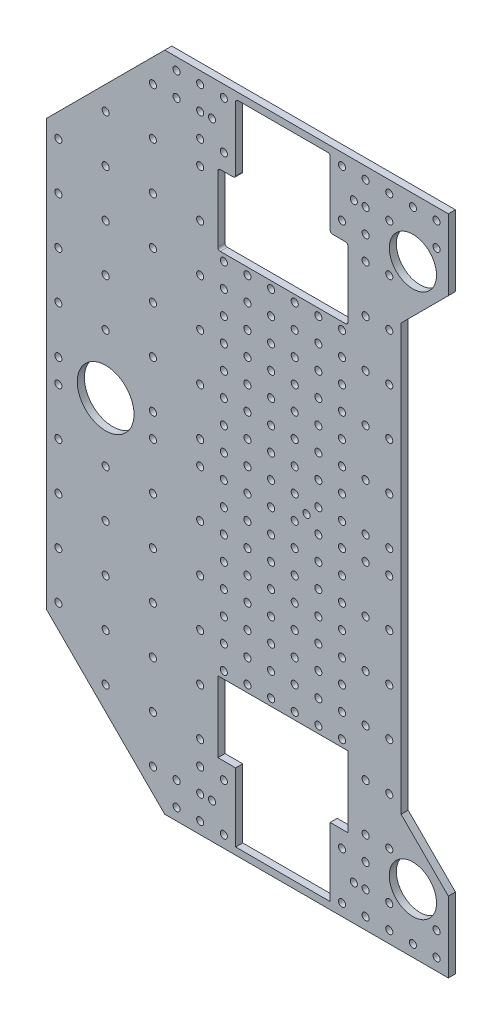
from build123d import *

# Parameters (mm, degrees)
SKETCH1_R                           = 1.5
MAIN_DEPTH                          = 3
MOTORCODERLEFTHOLE_DEPTH            = 179.070210872
FILLET1_R                           = 1
SKETCH7_R                           = 1.5
MOTORFIXHOLES_DEPTH                 = 179.070210872
MOTORFIXHOLELPATTERN_COUNT          = 8
MOTORFIXHOLELPATTERN_PITCH          = 10
SKETCH8_R                           = 1.5
LINEARBALLFIX_DEPTH                 = 179.070210872
LINEARBALLFIX2_COUNT                = 2
LINEARBALLFIX2_PITCH                = 60
SKETCH4_R                           = 1.5
BOTTOMLEFTHOLE_DEPTH                = 179.070210872
BOTTOMLEFTHOLELPATTERN_COUNT        = 9
BOTTOMLEFTHOLELPATTERN_PITCH        = 20
SKETCH5_R                           = 1.5
BOTTOMLEFTHOLE2_DEPTH               = 179.070210872
BOTTOMTOTOPPATTERN_COPY_1_SKETCH_R  = 1.5
BOTTOMTOTOPPATTERN_COPY_1_DEPTH     = 179.070210872
BOTTOMTOTOPPATTERN_COPY_2_SKETCH_R  = 1.5
BOTTOMTOTOPPATTERN_COPY_2_DEPTH     = 179.070210872
BOTTOMTOTOPPATTERN_COPY_3_SKETCH_R  = 1.5
BOTTOMTOTOPPATTERN_COPY_3_DEPTH     = 179.070210872
BOTTOMTOTOPPATTERN_COPY_4_SKETCH_R  = 1.5
BOTTOMTOTOPPATTERN_COPY_4_DEPTH     = 179.070210872
BOTTOMTOTOPPATTERN_COPY_5_SKETCH_R  = 1.5
BOTTOMTOTOPPATTERN_COPY_5_DEPTH     = 179.070210872
BOTTOMTOTOPPATTERN_COPY_6_SKETCH_R  = 1.5
BOTTOMTOTOPPATTERN_COPY_6_DEPTH     = 179.070210872
BOTTOMTOTOPPATTERN_COPY_7_SKETCH_R  = 1.5
BOTTOMTOTOPPATTERN_COPY_7_DEPTH     = 179.070210872
BOTTOMTOTOPPATTERN_COPY_8_SKETCH_R  = 1.5
BOTTOMTOTOPPATTERN_COPY_8_DEPTH     = 179.070210872
BOTTOMTOTOPPATTERN_COPY_9_SKETCH_R  = 1.5
BOTTOMTOTOPPATTERN_COPY_9_DEPTH     = 179.070210872
BOTTOMTOTOPPATTERN_COPY_10_SKETCH_R = 1.5
BOTTOMTOTOPPATTERN_COPY_10_DEPTH    = 179.070210872
BOTTOMTOTOPPATTERN_COPY_11_SKETCH_R = 1.5
BOTTOMTOTOPPATTERN_COPY_11_DEPTH    = 179.070210872
BOTTOMTOTOPPATTERN_COPY_12_SKETCH_R = 1.5
BOTTOMTOTOPPATTERN_COPY_12_DEPTH    = 179.070210872
BOTTOMTOTOPPATTERN_COPY_13_SKETCH_R = 1.5
BOTTOMTOTOPPATTERN_COPY_13_DEPTH    = 179.070210872
BOTTOMTOTOPPATTERN_COPY_14_SKETCH_R = 1.5
BOTTOMTOTOPPATTERN_COPY_14_DEPTH    = 179.070210872
BOTTOMTOTOPPATTERN_COPY_15_SKETCH_R = 1.5
BOTTOMTOTOPPATTERN_COPY_15_DEPTH    = 179.070210872
BOTTOMTOTOPPATTERN_COPY_16_SKETCH_R = 1.5
BOTTOMTOTOPPATTERN_COPY_16_DEPTH    = 179.070210872
BOTTOMTOTOPPATTERN_COPY_17_SKETCH_R = 1.5
BOTTOMTOTOPPATTERN_COPY_17_DEPTH    = 179.070210872
BOTTOMTOTOPPATTERN_COPY_18_SKETCH_R = 1.5
BOTTOMTOTOPPATTERN_COPY_18_DEPTH    = 179.070210872
BOTTOMTOTOPPATTERN_COPY_19_SKETCH_R = 1.5
BOTTOMTOTOPPATTERN_COPY_19_DEPTH    = 179.070210872
BOTTOMTOTOPPATTERN_COPY_20_SKETCH_R = 1.5
BOTTOMTOTOPPATTERN_COPY_20_DEPTH    = 179.070210872
BOTTOMTOTOPPATTERN_COPY_21_SKETCH_R = 1.5
BOTTOMTOTOPPATTERN_COPY_21_DEPTH    = 179.070210872
BOTTOMTOTOPPATTERN_COPY_22_SKETCH_R = 1.5
BOTTOMTOTOPPATTERN_COPY_22_DEPTH    = 179.070210872
BOTTOMTOTOPPATTERN_COPY_23_SKETCH_R = 1.5
BOTTOMTOTOPPATTERN_COPY_23_DEPTH    = 179.070210872
BOTTOMTOTOPPATTERN_COPY_24_SKETCH_R = 1.5
BOTTOMTOTOPPATTERN_COPY_24_DEPTH    = 179.070210872
BOTTOMTOTOPPATTERN_COPY_25_SKETCH_R = 1.5
BOTTOMTOTOPPATTERN_COPY_25_DEPTH    = 179.070210872
BOTTOMTOTOPPATTERN_COPY_26_SKETCH_R = 1.5
BOTTOMTOTOPPATTERN_COPY_26_DEPTH    = 179.070210872
BOTTOMTOTOPPATTERN_COPY_27_SKETCH_R = 1.5
BOTTOMTOTOPPATTERN_COPY_27_DEPTH    = 179.070210872
LPATTERN3_COUNT                     = 2
LPATTERN3_PITCH                     = 10
FRONTHOLES_COPY_1_SKETCH_R          = 1.5
FRONTHOLES_COPY_1_DEPTH             = 179.070210872
FRONTHOLES_COPY_2_SKETCH_R          = 1.5
FRONTHOLES_COPY_2_DEPTH             = 179.070210872
FRONTHOLES_COPY_3_SKETCH_R          = 1.5
FRONTHOLES_COPY_3_DEPTH             = 179.070210872
FRONTHOLES_COPY_4_SKETCH_R          = 1.5
FRONTHOLES_COPY_4_DEPTH             = 179.070210872
FRONTHOLES_COPY_5_SKETCH_R          = 1.5
FRONTHOLES_COPY_5_DEPTH             = 179.070210872
FRONTHOLES_COPY_6_SKETCH_R          = 1.5
FRONTHOLES_COPY_6_DEPTH             = 179.070210872
FRONTHOLES_COPY_7_SKETCH_R          = 1.5
FRONTHOLES_COPY_7_DEPTH             = 179.070210872
FRONTHOLES_COPY_8_SKETCH_R          = 1.5
FRONTHOLES_COPY_8_DEPTH             = 179.070210872
FRONTHOLES_COPY_9_SKETCH_R          = 1.5
FRONTHOLES_COPY_9_DEPTH             = 179.070210872
SKETCH9_R                           = 1.5
CUT_EXTRUDE2_DEPTH                  = 179.070210872
LPATTERN6_COPY_1_SKETCH_R           = 1.5
LPATTERN6_COPY_1_DEPTH              = 179.070210872
LPATTERN6_COPY_2_SKETCH_R           = 1.5
LPATTERN6_COPY_2_DEPTH              = 179.070210872
LPATTERN6_COPY_3_SKETCH_R           = 1.5
LPATTERN6_COPY_3_DEPTH              = 179.070210872
LPATTERN6_COPY_4_SKETCH_R           = 1.5
LPATTERN6_COPY_4_DEPTH              = 179.070210872
LPATTERN6_COPY_5_SKETCH_R           = 1.5
LPATTERN6_COPY_5_DEPTH              = 179.070210872
LPATTERN6_COPY_6_SKETCH_R           = 1.5
LPATTERN6_COPY_6_DEPTH              = 179.070210872
LPATTERN6_COPY_7_SKETCH_R           = 1.5
LPATTERN6_COPY_7_DEPTH              = 179.070210872
LPATTERN6_COPY_8_SKETCH_R           = 1.5
LPATTERN6_COPY_8_DEPTH              = 179.070210872
LPATTERN6_COPY_9_SKETCH_R           = 1.5
LPATTERN6_COPY_9_DEPTH              = 179.070210872
MIRROR1_COPY_1_SKETCH_R             = 1.5
MIRROR1_COPY_1_DEPTH                = 179.070210872
MIRROR1_COPY_2_SKETCH_R             = 1.5
MIRROR1_COPY_2_DEPTH                = 179.070210872
MIRROR1_COPY_3_SKETCH_R             = 1.5
MIRROR1_COPY_3_DEPTH                = 179.070210872
MIRROR1_COPY_4_SKETCH_R             = 1.5
MIRROR1_COPY_4_DEPTH                = 179.070210872
MIRROR1_COPY_5_SKETCH_R             = 1.5
MIRROR1_COPY_5_DEPTH                = 179.070210872
MIRROR1_COPY_6_SKETCH_R             = 1.5
MIRROR1_COPY_6_DEPTH                = 179.070210872
MIRROR1_COPY_7_SKETCH_R             = 1.5
MIRROR1_COPY_7_DEPTH                = 179.070210872
MIRROR1_COPY_8_SKETCH_R             = 1.5
MIRROR1_COPY_8_DEPTH                = 179.070210872
MIRROR1_COPY_9_SKETCH_R             = 1.5
MIRROR1_COPY_9_DEPTH                = 179.070210872
MIRROR1_COPY_10_SKETCH_R            = 1.5
MIRROR1_COPY_10_DEPTH               = 179.070210872
MIRROR1_COPY_11_SKETCH_R            = 1.5
MIRROR1_COPY_11_DEPTH               = 179.070210872
MIRROR1_COPY_12_SKETCH_R            = 1.5
MIRROR1_COPY_12_DEPTH               = 179.070210872
MIRROR1_COPY_13_SKETCH_R            = 1.5
MIRROR1_COPY_13_DEPTH               = 179.070210872
MIRROR1_COPY_14_SKETCH_R            = 1.5
MIRROR1_COPY_14_DEPTH               = 179.070210872
MIRROR1_COPY_15_SKETCH_R            = 1.5
MIRROR1_COPY_15_DEPTH               = 179.070210872
MIRROR1_COPY_16_SKETCH_R            = 1.5
MIRROR1_COPY_16_DEPTH               = 179.070210872
MIRROR1_COPY_17_SKETCH_R            = 1.5
MIRROR1_COPY_17_DEPTH               = 179.070210872
MIRROR1_COPY_18_SKETCH_R            = 1.5
MIRROR1_COPY_18_DEPTH               = 179.070210872
MIRROR1_COPY_19_SKETCH_R            = 1.5
MIRROR1_COPY_19_DEPTH               = 179.070210872
MIRROR1_COPY_20_SKETCH_R            = 1.5
MIRROR1_COPY_20_DEPTH               = 179.070210872
MIRROR1_COPY_21_SKETCH_R            = 1.5
MIRROR1_COPY_21_DEPTH               = 179.070210872
MIRROR1_COPY_22_SKETCH_R            = 1.5
MIRROR1_COPY_22_DEPTH               = 179.070210872
MIRROR1_COPY_23_SKETCH_R            = 1.5
MIRROR1_COPY_23_DEPTH               = 179.070210872
MIRROR1_COPY_24_SKETCH_R            = 1.5
MIRROR1_COPY_24_DEPTH               = 179.070210872
MIRROR1_COPY_25_SKETCH_R            = 1.5
MIRROR1_COPY_25_DEPTH               = 179.070210872
MIRROR1_COPY_26_SKETCH_R            = 1.5
MIRROR1_COPY_26_DEPTH               = 179.070210872
MIRROR1_COPY_27_SKETCH_R            = 1.5
MIRROR1_COPY_27_DEPTH               = 179.070210872
MIRROR1_COPY_28_SKETCH_R            = 1.5
MIRROR1_COPY_28_DEPTH               = 179.070210872
MIRROR1_COPY_29_SKETCH_R            = 1.5
MIRROR1_COPY_29_DEPTH               = 179.070210872
MIRROR1_COPY_30_SKETCH_R            = 1.5
MIRROR1_COPY_30_DEPTH               = 179.070210872
MIRROR1_COPY_31_SKETCH_R            = 1.5
MIRROR1_COPY_31_DEPTH               = 179.070210872
MIRROR1_COPY_32_SKETCH_R            = 1.5
MIRROR1_COPY_32_DEPTH               = 179.070210872
MIRROR1_COPY_33_SKETCH_R            = 1.5
MIRROR1_COPY_33_DEPTH               = 179.070210872
MIRROR1_COPY_34_SKETCH_R            = 1.5
MIRROR1_COPY_34_DEPTH               = 179.070210872
MIRROR1_COPY_35_SKETCH_R            = 1.5
MIRROR1_COPY_35_DEPTH               = 179.070210872
MIRROR1_COPY_36_SKETCH_R            = 1.5
MIRROR1_COPY_36_DEPTH               = 179.070210872
MIRROR1_COPY_37_SKETCH_R            = 1.5
MIRROR1_COPY_37_DEPTH               = 179.070210872
MIRROR1_COPY_38_SKETCH_R            = 1.5
MIRROR1_COPY_38_DEPTH               = 179.070210872
MIRROR1_COPY_39_SKETCH_R            = 1.5
MIRROR1_COPY_39_DEPTH               = 179.070210872
MIRROR1_COPY_40_SKETCH_R            = 1.5
MIRROR1_COPY_40_DEPTH               = 179.070210872
MIRROR1_COPY_41_SKETCH_R            = 1.5
MIRROR1_COPY_41_DEPTH               = 179.070210872
MIRROR1_COPY_42_SKETCH_R            = 1.5
MIRROR1_COPY_42_DEPTH               = 179.070210872
MIRROR1_COPY_43_SKETCH_R            = 1.5
MIRROR1_COPY_43_DEPTH               = 179.070210872
MIRROR1_COPY_44_SKETCH_R            = 1.5
MIRROR1_COPY_44_DEPTH               = 179.070210872
MIRROR1_COPY_45_SKETCH_R            = 1.5
MIRROR1_COPY_45_DEPTH               = 179.070210872
MIRROR1_COPY_46_SKETCH_R            = 1.5
MIRROR1_COPY_46_DEPTH               = 179.070210872
MIRROR1_COPY_47_SKETCH_R            = 1.5
MIRROR1_COPY_47_DEPTH               = 179.070210872
MIRROR1_COPY_48_SKETCH_R            = 1.5
MIRROR1_COPY_48_DEPTH               = 179.070210872
MIRROR1_COPY_49_SKETCH_R            = 1.5
MIRROR1_COPY_49_DEPTH               = 179.070210872
MIRROR1_COPY_50_SKETCH_R            = 1.5
MIRROR1_COPY_50_DEPTH               = 179.070210872
MIRROR1_COPY_51_SKETCH_R            = 1.5
MIRROR1_COPY_51_DEPTH               = 179.070210872
MIRROR1_COPY_52_SKETCH_R            = 1.5
MIRROR1_COPY_52_DEPTH               = 179.070210872
MIRROR1_COPY_53_SKETCH_R            = 1.5
MIRROR1_COPY_53_DEPTH               = 179.070210872
MIRROR1_COPY_54_SKETCH_R            = 1.5
MIRROR1_COPY_54_DEPTH               = 179.070210872
MIRROR1_COPY_55_SKETCH_R            = 1.5
MIRROR1_COPY_55_DEPTH               = 179.070210872
MIRROR1_COPY_56_SKETCH_R            = 1.5
MIRROR1_COPY_56_DEPTH               = 179.070210872
MIRROR1_COPY_57_SKETCH_R            = 1.5
MIRROR1_COPY_57_DEPTH               = 179.070210872
MIRROR1_COPY_58_SKETCH_R            = 1.5
MIRROR1_COPY_58_DEPTH               = 179.070210872
MIRROR1_COPY_59_SKETCH_R            = 1.5
MIRROR1_COPY_59_DEPTH               = 179.070210872
MIRROR1_COPY_60_SKETCH_R            = 1.5
MIRROR1_COPY_60_DEPTH               = 179.070210872
MIRROR1_COPY_61_SKETCH_R            = 1.5
MIRROR1_COPY_61_DEPTH               = 179.070210872
MIRROR1_COPY_62_SKETCH_R            = 1.5
MIRROR1_COPY_62_DEPTH               = 179.070210872
SKETCH3_R                           = 12
SKETCH3_R_2                         = 10
BIGHOLES_DEPTH                      = 179.070210872


with BuildPart() as part:
    # Sketch1 → Main (new body)
    with BuildSketch(Plane.XY):
        Polygon((-110, 90), (-110, -90), (-60, -140), (60, -140), (60, -110), (40, -90), (40, 90), (60, 110), (60, 140), (-60, 140), align=None)
        Circle(SKETCH1_R, mode=Mode.SUBTRACT)
    extrude(amount=MAIN_DEPTH)

    # Sketch2 → MotorCoderLeftHole (cut, through all)
    with BuildSketch(Plane.XY.offset(3)):
        Polygon((-37.5, 108), (-37.5, 78), (17.5, 78), (17.5, 108), (10, 108), (10, 137), (-30, 137), (-30, 108), align=None)
    motorcoderlefthole = extrude(amount=-MOTORCODERLEFTHOLE_DEPTH, mode=Mode.SUBTRACT)

    # Fillet1
    fillet1_edges = [part.edges().sort_by_distance(p)[0] for p in [
        (-30, 137, 1.5),
        (10, 108, 1.5),
        (17.5, 108, 1.5),
        (10, 137, 1.5),
        (17.5, 78, 1.5),
        (-37.5, 78, 1.5),
        (-37.5, 108, 1.5),
        (-30, 108, 1.5),
    ]]
    fillet(fillet1_edges, radius=FILLET1_R)

    # Sketch7 → MotorFixHoles (cut, through all)
    with BuildSketch(Plane.XY.offset(3)):
        with Locations((-15, 75)):
            Circle(SKETCH7_R)
        with Locations((-25, 75)):
            Circle(SKETCH7_R)
        with Locations((-5, 75)):
            Circle(SKETCH7_R)
        with Locations((-35, 75)):
            Circle(SKETCH7_R)
        with Locations((5, 75)):
            Circle(SKETCH7_R)
        with Locations((15, 75)):
            Circle(SKETCH7_R)
    motorfixholes = extrude(amount=-MOTORFIXHOLES_DEPTH, mode=Mode.SUBTRACT)

    # MotorFixHoleLPattern: MotorFixHoles ×8
    with Locations(*[(0, -i * MOTORFIXHOLELPATTERN_PITCH, 0) for i in range(1, MOTORFIXHOLELPATTERN_COUNT)]):
        add(motorfixholes, mode=Mode.SUBTRACT)

    # Sketch8 → LinearBallFix (cut, through all)
    with BuildSketch(Plane.XY.offset(3)):
        with Locations((-40, 125)):
            Circle(SKETCH8_R)
        with Locations((-45, 115)):
            Circle(SKETCH8_R)
        with Locations((-35, 115)):
            Circle(SKETCH8_R)
        with Locations((-45, 135)):
            Circle(SKETCH8_R)
        with Locations((-35, 135)):
            Circle(SKETCH8_R)
    linearballfix = extrude(amount=-LINEARBALLFIX_DEPTH, mode=Mode.SUBTRACT)

    # LinearBallFix2: LinearBallFix ×2
    with Locations(*[(i * LINEARBALLFIX2_PITCH, 0, 0) for i in range(1, LINEARBALLFIX2_COUNT)]):
        add(linearballfix, mode=Mode.SUBTRACT)

    # Sketch4 → BottomLeftHole (cut, through all)
    with BuildSketch(Plane.XY.offset(3)):
        with Locations((-105, 5)):
            Circle(SKETCH4_R)
    bottomlefthole = extrude(amount=-BOTTOMLEFTHOLE_DEPTH, mode=Mode.SUBTRACT)

    # BottomLeftHoleLPattern: BottomLeftHole ×9
    with Locations(*[(0, i * BOTTOMLEFTHOLELPATTERN_PITCH, 0) for i in range(1, BOTTOMLEFTHOLELPATTERN_COUNT)]):
        add(bottomlefthole, mode=Mode.SUBTRACT)

    # Sketch5 → BottomLeftHole2 (cut, through all)
    with BuildSketch(Plane.XY.offset(3)):
        with Locations((-55, 135)):
            Circle(SKETCH5_R)
        with Locations((35, 135)):
            Circle(SKETCH5_R)
        with Locations((55, 135)):
            Circle(SKETCH5_R)
    bottomlefthole2 = extrude(amount=-BOTTOMLEFTHOLE2_DEPTH, mode=Mode.SUBTRACT)

    # BottomToTopPattern copy 1 sketch → BottomToTopPattern copy 1 (cut, through all)
    with BuildSketch(Plane(origin=(20, 20, 3), x_dir=(1, 0, 0), z_dir=(0, 0, 1))):
        with Locations((-105, 5)):
            Circle(BOTTOMTOTOPPATTERN_COPY_1_SKETCH_R)
    extrude(amount=-BOTTOMTOTOPPATTERN_COPY_1_DEPTH, mode=Mode.SUBTRACT)

    # BottomToTopPattern copy 2 sketch → BottomToTopPattern copy 2 (cut, through all)
    with BuildSketch(Plane(origin=(40, 20, 3), x_dir=(1, 0, 0), z_dir=(0, 0, 1))):
        with Locations((-105, 5)):
            Circle(BOTTOMTOTOPPATTERN_COPY_2_SKETCH_R)
    extrude(amount=-BOTTOMTOTOPPATTERN_COPY_2_DEPTH, mode=Mode.SUBTRACT)

    # BottomToTopPattern copy 3 sketch → BottomToTopPattern copy 3 (cut, through all)
    with BuildSketch(Plane(origin=(60, 20, 3), x_dir=(1, 0, 0), z_dir=(0, 0, 1))):
        with Locations((-105, 5)):
            Circle(BOTTOMTOTOPPATTERN_COPY_3_SKETCH_R)
    extrude(amount=-BOTTOMTOTOPPATTERN_COPY_3_DEPTH, mode=Mode.SUBTRACT)

    # BottomToTopPattern copy 4 sketch → BottomToTopPattern copy 4 (cut, through all)
    with BuildSketch(Plane(origin=(20, 40, 3), x_dir=(1, 0, 0), z_dir=(0, 0, 1))):
        with Locations((-105, 5)):
            Circle(BOTTOMTOTOPPATTERN_COPY_4_SKETCH_R)
    extrude(amount=-BOTTOMTOTOPPATTERN_COPY_4_DEPTH, mode=Mode.SUBTRACT)

    # BottomToTopPattern copy 5 sketch → BottomToTopPattern copy 5 (cut, through all)
    with BuildSketch(Plane(origin=(40, 40, 3), x_dir=(1, 0, 0), z_dir=(0, 0, 1))):
        with Locations((-105, 5)):
            Circle(BOTTOMTOTOPPATTERN_COPY_5_SKETCH_R)
    extrude(amount=-BOTTOMTOTOPPATTERN_COPY_5_DEPTH, mode=Mode.SUBTRACT)

    # BottomToTopPattern copy 6 sketch → BottomToTopPattern copy 6 (cut, through all)
    with BuildSketch(Plane(origin=(60, 40, 3), x_dir=(1, 0, 0), z_dir=(0, 0, 1))):
        with Locations((-105, 5)):
            Circle(BOTTOMTOTOPPATTERN_COPY_6_SKETCH_R)
    extrude(amount=-BOTTOMTOTOPPATTERN_COPY_6_DEPTH, mode=Mode.SUBTRACT)

    # BottomToTopPattern copy 7 sketch → BottomToTopPattern copy 7 (cut, through all)
    with BuildSketch(Plane(origin=(20, 60, 3), x_dir=(1, 0, 0), z_dir=(0, 0, 1))):
        with Locations((-105, 5)):
            Circle(BOTTOMTOTOPPATTERN_COPY_7_SKETCH_R)
    extrude(amount=-BOTTOMTOTOPPATTERN_COPY_7_DEPTH, mode=Mode.SUBTRACT)

    # BottomToTopPattern copy 8 sketch → BottomToTopPattern copy 8 (cut, through all)
    with BuildSketch(Plane(origin=(40, 60, 3), x_dir=(1, 0, 0), z_dir=(0, 0, 1))):
        with Locations((-105, 5)):
            Circle(BOTTOMTOTOPPATTERN_COPY_8_SKETCH_R)
    extrude(amount=-BOTTOMTOTOPPATTERN_COPY_8_DEPTH, mode=Mode.SUBTRACT)

    # BottomToTopPattern copy 9 sketch → BottomToTopPattern copy 9 (cut, through all)
    with BuildSketch(Plane(origin=(60, 60, 3), x_dir=(1, 0, 0), z_dir=(0, 0, 1))):
        with Locations((-105, 5)):
            Circle(BOTTOMTOTOPPATTERN_COPY_9_SKETCH_R)
    extrude(amount=-BOTTOMTOTOPPATTERN_COPY_9_DEPTH, mode=Mode.SUBTRACT)

    # BottomToTopPattern copy 10 sketch → BottomToTopPattern copy 10 (cut, through all)
    with BuildSketch(Plane(origin=(20, 80, 3), x_dir=(1, 0, 0), z_dir=(0, 0, 1))):
        with Locations((-105, 5)):
            Circle(BOTTOMTOTOPPATTERN_COPY_10_SKETCH_R)
    extrude(amount=-BOTTOMTOTOPPATTERN_COPY_10_DEPTH, mode=Mode.SUBTRACT)

    # BottomToTopPattern copy 11 sketch → BottomToTopPattern copy 11 (cut, through all)
    with BuildSketch(Plane(origin=(40, 80, 3), x_dir=(1, 0, 0), z_dir=(0, 0, 1))):
        with Locations((-105, 5)):
            Circle(BOTTOMTOTOPPATTERN_COPY_11_SKETCH_R)
    extrude(amount=-BOTTOMTOTOPPATTERN_COPY_11_DEPTH, mode=Mode.SUBTRACT)

    # BottomToTopPattern copy 12 sketch → BottomToTopPattern copy 12 (cut, through all)
    with BuildSketch(Plane(origin=(60, 80, 3), x_dir=(1, 0, 0), z_dir=(0, 0, 1))):
        with Locations((-105, 5)):
            Circle(BOTTOMTOTOPPATTERN_COPY_12_SKETCH_R)
    extrude(amount=-BOTTOMTOTOPPATTERN_COPY_12_DEPTH, mode=Mode.SUBTRACT)

    # BottomToTopPattern copy 13 sketch → BottomToTopPattern copy 13 (cut, through all)
    with BuildSketch(Plane(origin=(20, 100, 3), x_dir=(1, 0, 0), z_dir=(0, 0, 1))):
        with Locations((-105, 5)):
            Circle(BOTTOMTOTOPPATTERN_COPY_13_SKETCH_R)
    extrude(amount=-BOTTOMTOTOPPATTERN_COPY_13_DEPTH, mode=Mode.SUBTRACT)

    # BottomToTopPattern copy 14 sketch → BottomToTopPattern copy 14 (cut, through all)
    with BuildSketch(Plane(origin=(40, 100, 3), x_dir=(1, 0, 0), z_dir=(0, 0, 1))):
        with Locations((-105, 5)):
            Circle(BOTTOMTOTOPPATTERN_COPY_14_SKETCH_R)
    extrude(amount=-BOTTOMTOTOPPATTERN_COPY_14_DEPTH, mode=Mode.SUBTRACT)

    # BottomToTopPattern copy 15 sketch → BottomToTopPattern copy 15 (cut, through all)
    with BuildSketch(Plane(origin=(60, 100, 3), x_dir=(1, 0, 0), z_dir=(0, 0, 1))):
        with Locations((-105, 5)):
            Circle(BOTTOMTOTOPPATTERN_COPY_15_SKETCH_R)
    extrude(amount=-BOTTOMTOTOPPATTERN_COPY_15_DEPTH, mode=Mode.SUBTRACT)

    # BottomToTopPattern copy 16 sketch → BottomToTopPattern copy 16 (cut, through all)
    with BuildSketch(Plane(origin=(20, 120, 3), x_dir=(1, 0, 0), z_dir=(0, 0, 1))):
        with Locations((-105, 5)):
            Circle(BOTTOMTOTOPPATTERN_COPY_16_SKETCH_R)
    extrude(amount=-BOTTOMTOTOPPATTERN_COPY_16_DEPTH, mode=Mode.SUBTRACT)

    # BottomToTopPattern copy 17 sketch → BottomToTopPattern copy 17 (cut, through all)
    with BuildSketch(Plane(origin=(40, 120, 3), x_dir=(1, 0, 0), z_dir=(0, 0, 1))):
        with Locations((-105, 5)):
            Circle(BOTTOMTOTOPPATTERN_COPY_17_SKETCH_R)
    extrude(amount=-BOTTOMTOTOPPATTERN_COPY_17_DEPTH, mode=Mode.SUBTRACT)

    # BottomToTopPattern copy 18 sketch → BottomToTopPattern copy 18 (cut, through all)
    with BuildSketch(Plane(origin=(60, 120, 3), x_dir=(1, 0, 0), z_dir=(0, 0, 1))):
        with Locations((-105, 5)):
            Circle(BOTTOMTOTOPPATTERN_COPY_18_SKETCH_R)
    extrude(amount=-BOTTOMTOTOPPATTERN_COPY_18_DEPTH, mode=Mode.SUBTRACT)

    # BottomToTopPattern copy 19 sketch → BottomToTopPattern copy 19 (cut, through all)
    with BuildSketch(Plane(origin=(20, 140, 3), x_dir=(1, 0, 0), z_dir=(0, 0, 1))):
        with Locations((-105, 5)):
            Circle(BOTTOMTOTOPPATTERN_COPY_19_SKETCH_R)
    extrude(amount=-BOTTOMTOTOPPATTERN_COPY_19_DEPTH, mode=Mode.SUBTRACT)

    # BottomToTopPattern copy 20 sketch → BottomToTopPattern copy 20 (cut, through all)
    with BuildSketch(Plane(origin=(40, 140, 3), x_dir=(1, 0, 0), z_dir=(0, 0, 1))):
        with Locations((-105, 5)):
            Circle(BOTTOMTOTOPPATTERN_COPY_20_SKETCH_R)
    extrude(amount=-BOTTOMTOTOPPATTERN_COPY_20_DEPTH, mode=Mode.SUBTRACT)

    # BottomToTopPattern copy 21 sketch → BottomToTopPattern copy 21 (cut, through all)
    with BuildSketch(Plane(origin=(60, 140, 3), x_dir=(1, 0, 0), z_dir=(0, 0, 1))):
        with Locations((-105, 5)):
            Circle(BOTTOMTOTOPPATTERN_COPY_21_SKETCH_R)
    extrude(amount=-BOTTOMTOTOPPATTERN_COPY_21_DEPTH, mode=Mode.SUBTRACT)

    # BottomToTopPattern copy 22 sketch → BottomToTopPattern copy 22 (cut, through all)
    with BuildSketch(Plane(origin=(20, 160, 3), x_dir=(1, 0, 0), z_dir=(0, 0, 1))):
        with Locations((-105, 5)):
            Circle(BOTTOMTOTOPPATTERN_COPY_22_SKETCH_R)
    extrude(amount=-BOTTOMTOTOPPATTERN_COPY_22_DEPTH, mode=Mode.SUBTRACT)

    # BottomToTopPattern copy 23 sketch → BottomToTopPattern copy 23 (cut, through all)
    with BuildSketch(Plane(origin=(40, 160, 3), x_dir=(1, 0, 0), z_dir=(0, 0, 1))):
        with Locations((-105, 5)):
            Circle(BOTTOMTOTOPPATTERN_COPY_23_SKETCH_R)
    extrude(amount=-BOTTOMTOTOPPATTERN_COPY_23_DEPTH, mode=Mode.SUBTRACT)

    # BottomToTopPattern copy 24 sketch → BottomToTopPattern copy 24 (cut, through all)
    with BuildSketch(Plane(origin=(60, 160, 3), x_dir=(1, 0, 0), z_dir=(0, 0, 1))):
        with Locations((-105, 5)):
            Circle(BOTTOMTOTOPPATTERN_COPY_24_SKETCH_R)
    extrude(amount=-BOTTOMTOTOPPATTERN_COPY_24_DEPTH, mode=Mode.SUBTRACT)

    # BottomToTopPattern copy 25 sketch → BottomToTopPattern copy 25 (cut, through all)
    with BuildSketch(Plane(origin=(20, 0, 3), x_dir=(1, 0, 0), z_dir=(0, 0, 1))):
        with Locations((-105, 5)):
            Circle(BOTTOMTOTOPPATTERN_COPY_25_SKETCH_R)
    extrude(amount=-BOTTOMTOTOPPATTERN_COPY_25_DEPTH, mode=Mode.SUBTRACT)

    # BottomToTopPattern copy 26 sketch → BottomToTopPattern copy 26 (cut, through all)
    with BuildSketch(Plane(origin=(40, 0, 3), x_dir=(1, 0, 0), z_dir=(0, 0, 1))):
        with Locations((-105, 5)):
            Circle(BOTTOMTOTOPPATTERN_COPY_26_SKETCH_R)
    extrude(amount=-BOTTOMTOTOPPATTERN_COPY_26_DEPTH, mode=Mode.SUBTRACT)

    # BottomToTopPattern copy 27 sketch → BottomToTopPattern copy 27 (cut, through all)
    with BuildSketch(Plane(origin=(60, 0, 3), x_dir=(1, 0, 0), z_dir=(0, 0, 1))):
        with Locations((-105, 5)):
            Circle(BOTTOMTOTOPPATTERN_COPY_27_SKETCH_R)
    extrude(amount=-BOTTOMTOTOPPATTERN_COPY_27_DEPTH, mode=Mode.SUBTRACT)

    # LPattern3: BottomLeftHole2 ×2
    with Locations(*[(0, -i * LPATTERN3_PITCH, 0) for i in range(1, LPATTERN3_COUNT)]):
        add(bottomlefthole2, mode=Mode.SUBTRACT)

    # FrontHoles copy 1 sketch → FrontHoles copy 1 (cut, through all)
    with BuildSketch(Plane(origin=(140, 20, 3), x_dir=(1, 0, 0), z_dir=(0, 0, 1))):
        with Locations((-105, 5)):
            Circle(FRONTHOLES_COPY_1_SKETCH_R)
    extrude(amount=-FRONTHOLES_COPY_1_DEPTH, mode=Mode.SUBTRACT)

    # FrontHoles copy 2 sketch → FrontHoles copy 2 (cut, through all)
    with BuildSketch(Plane(origin=(140, 40, 3), x_dir=(1, 0, 0), z_dir=(0, 0, 1))):
        with Locations((-105, 5)):
            Circle(FRONTHOLES_COPY_2_SKETCH_R)
    extrude(amount=-FRONTHOLES_COPY_2_DEPTH, mode=Mode.SUBTRACT)

    # FrontHoles copy 3 sketch → FrontHoles copy 3 (cut, through all)
    with BuildSketch(Plane(origin=(140, 60, 3), x_dir=(1, 0, 0), z_dir=(0, 0, 1))):
        with Locations((-105, 5)):
            Circle(FRONTHOLES_COPY_3_SKETCH_R)
    extrude(amount=-FRONTHOLES_COPY_3_DEPTH, mode=Mode.SUBTRACT)

    # FrontHoles copy 4 sketch → FrontHoles copy 4 (cut, through all)
    with BuildSketch(Plane(origin=(140, 80, 3), x_dir=(1, 0, 0), z_dir=(0, 0, 1))):
        with Locations((-105, 5)):
            Circle(FRONTHOLES_COPY_4_SKETCH_R)
    extrude(amount=-FRONTHOLES_COPY_4_DEPTH, mode=Mode.SUBTRACT)

    # FrontHoles copy 5 sketch → FrontHoles copy 5 (cut, through all)
    with BuildSketch(Plane(origin=(140, 100, 3), x_dir=(1, 0, 0), z_dir=(0, 0, 1))):
        with Locations((-105, 5)):
            Circle(FRONTHOLES_COPY_5_SKETCH_R)
    extrude(amount=-FRONTHOLES_COPY_5_DEPTH, mode=Mode.SUBTRACT)

    # FrontHoles copy 6 sketch → FrontHoles copy 6 (cut, through all)
    with BuildSketch(Plane(origin=(140, 120, 3), x_dir=(1, 0, 0), z_dir=(0, 0, 1))):
        with Locations((-105, 5)):
            Circle(FRONTHOLES_COPY_6_SKETCH_R)
    extrude(amount=-FRONTHOLES_COPY_6_DEPTH, mode=Mode.SUBTRACT)

    # FrontHoles copy 7 sketch → FrontHoles copy 7 (cut, through all)
    with BuildSketch(Plane(origin=(140, 140, 3), x_dir=(1, 0, 0), z_dir=(0, 0, 1))):
        with Locations((-105, 5)):
            Circle(FRONTHOLES_COPY_7_SKETCH_R)
    extrude(amount=-FRONTHOLES_COPY_7_DEPTH, mode=Mode.SUBTRACT)

    # FrontHoles copy 8 sketch → FrontHoles copy 8 (cut, through all)
    with BuildSketch(Plane(origin=(140, 160, 3), x_dir=(1, 0, 0), z_dir=(0, 0, 1))):
        with Locations((-105, 5)):
            Circle(FRONTHOLES_COPY_8_SKETCH_R)
    extrude(amount=-FRONTHOLES_COPY_8_DEPTH, mode=Mode.SUBTRACT)

    # FrontHoles copy 9 sketch → FrontHoles copy 9 (cut, through all)
    with BuildSketch(Plane(origin=(140, 0, 3), x_dir=(1, 0, 0), z_dir=(0, 0, 1))):
        with Locations((-105, 5)):
            Circle(FRONTHOLES_COPY_9_SKETCH_R)
    extrude(amount=-FRONTHOLES_COPY_9_DEPTH, mode=Mode.SUBTRACT)

    # Sketch9 → Cut-Extrude2 (cut, through all)
    with BuildSketch(Plane.XY.offset(3)):
        with Locations((-85, 25)):
            Circle(SKETCH9_R)
        with Locations((-65, 25)):
            Circle(SKETCH9_R)
        with Locations((-45, 25)):
            Circle(SKETCH9_R)
        with Locations((-65, 45)):
            Circle(SKETCH9_R)
        with Locations((35, 105)):
            Circle(SKETCH9_R)
        with Locations((45, 135)):
            Circle(SKETCH9_R)
    cut_extrude2 = extrude(amount=-CUT_EXTRUDE2_DEPTH, mode=Mode.SUBTRACT)

    # LPattern6 copy 1 sketch → LPattern6 copy 1 (cut, through all)
    with BuildSketch(Plane(origin=(130, 20, 3), x_dir=(1, 0, 0), z_dir=(0, 0, 1))):
        with Locations((-105, 5)):
            Circle(LPATTERN6_COPY_1_SKETCH_R)
    extrude(amount=-LPATTERN6_COPY_1_DEPTH, mode=Mode.SUBTRACT)

    # LPattern6 copy 2 sketch → LPattern6 copy 2 (cut, through all)
    with BuildSketch(Plane(origin=(130, 40, 3), x_dir=(1, 0, 0), z_dir=(0, 0, 1))):
        with Locations((-105, 5)):
            Circle(LPATTERN6_COPY_2_SKETCH_R)
    extrude(amount=-LPATTERN6_COPY_2_DEPTH, mode=Mode.SUBTRACT)

    # LPattern6 copy 3 sketch → LPattern6 copy 3 (cut, through all)
    with BuildSketch(Plane(origin=(130, 60, 3), x_dir=(1, 0, 0), z_dir=(0, 0, 1))):
        with Locations((-105, 5)):
            Circle(LPATTERN6_COPY_3_SKETCH_R)
    extrude(amount=-LPATTERN6_COPY_3_DEPTH, mode=Mode.SUBTRACT)

    # LPattern6 copy 4 sketch → LPattern6 copy 4 (cut, through all)
    with BuildSketch(Plane(origin=(130, 80, 3), x_dir=(1, 0, 0), z_dir=(0, 0, 1))):
        with Locations((-105, 5)):
            Circle(LPATTERN6_COPY_4_SKETCH_R)
    extrude(amount=-LPATTERN6_COPY_4_DEPTH, mode=Mode.SUBTRACT)

    # LPattern6 copy 5 sketch → LPattern6 copy 5 (cut, through all)
    with BuildSketch(Plane(origin=(130, 100, 3), x_dir=(1, 0, 0), z_dir=(0, 0, 1))):
        with Locations((-105, 5)):
            Circle(LPATTERN6_COPY_5_SKETCH_R)
    extrude(amount=-LPATTERN6_COPY_5_DEPTH, mode=Mode.SUBTRACT)

    # LPattern6 copy 6 sketch → LPattern6 copy 6 (cut, through all)
    with BuildSketch(Plane(origin=(130, 120, 3), x_dir=(1, 0, 0), z_dir=(0, 0, 1))):
        with Locations((-105, 5)):
            Circle(LPATTERN6_COPY_6_SKETCH_R)
    extrude(amount=-LPATTERN6_COPY_6_DEPTH, mode=Mode.SUBTRACT)

    # LPattern6 copy 7 sketch → LPattern6 copy 7 (cut, through all)
    with BuildSketch(Plane(origin=(130, 140, 3), x_dir=(1, 0, 0), z_dir=(0, 0, 1))):
        with Locations((-105, 5)):
            Circle(LPATTERN6_COPY_7_SKETCH_R)
    extrude(amount=-LPATTERN6_COPY_7_DEPTH, mode=Mode.SUBTRACT)

    # LPattern6 copy 8 sketch → LPattern6 copy 8 (cut, through all)
    with BuildSketch(Plane(origin=(130, 160, 3), x_dir=(1, 0, 0), z_dir=(0, 0, 1))):
        with Locations((-105, 5)):
            Circle(LPATTERN6_COPY_8_SKETCH_R)
    extrude(amount=-LPATTERN6_COPY_8_DEPTH, mode=Mode.SUBTRACT)

    # LPattern6 copy 9 sketch → LPattern6 copy 9 (cut, through all)
    with BuildSketch(Plane(origin=(130, 0, 3), x_dir=(1, 0, 0), z_dir=(0, 0, 1))):
        with Locations((-105, 5)):
            Circle(LPATTERN6_COPY_9_SKETCH_R)
    extrude(amount=-LPATTERN6_COPY_9_DEPTH, mode=Mode.SUBTRACT)

    # Mirror1: MotorCoderLeftHole, MotorFixHoles, LinearBallFix, BottomLeftHole, BottomLeftHole2, Cut-Extrude2 across plane
    add(motorcoderlefthole.mirror(Plane.ZX), mode=Mode.SUBTRACT)
    add(motorfixholes.mirror(Plane.ZX), mode=Mode.SUBTRACT)
    add(linearballfix.mirror(Plane.ZX), mode=Mode.SUBTRACT)
    add(bottomlefthole.mirror(Plane.ZX), mode=Mode.SUBTRACT)
    add(bottomlefthole2.mirror(Plane.ZX), mode=Mode.SUBTRACT)
    add(cut_extrude2.mirror(Plane.ZX), mode=Mode.SUBTRACT)

    # Mirror1 copy 1 sketch → Mirror1 copy 1 (cut, through all)
    with BuildSketch(Plane(origin=(0, 10, 3), x_dir=(1, 0, 0), z_dir=(0, 0, 1))):
        with Locations((-15, -75)):
            Circle(MIRROR1_COPY_1_SKETCH_R)
        with Locations((-25, -75)):
            Circle(MIRROR1_COPY_1_SKETCH_R)
        with Locations((-5, -75)):
            Circle(MIRROR1_COPY_1_SKETCH_R)
        with Locations((-35, -75)):
            Circle(MIRROR1_COPY_1_SKETCH_R)
        with Locations((5, -75)):
            Circle(MIRROR1_COPY_1_SKETCH_R)
        with Locations((15, -75)):
            Circle(MIRROR1_COPY_1_SKETCH_R)
    extrude(amount=-MIRROR1_COPY_1_DEPTH, mode=Mode.SUBTRACT)

    # Mirror1 copy 2 sketch → Mirror1 copy 2 (cut, through all)
    with BuildSketch(Plane(origin=(0, 20, 3), x_dir=(1, 0, 0), z_dir=(0, 0, 1))):
        with Locations((-15, -75)):
            Circle(MIRROR1_COPY_2_SKETCH_R)
        with Locations((-25, -75)):
            Circle(MIRROR1_COPY_2_SKETCH_R)
        with Locations((-5, -75)):
            Circle(MIRROR1_COPY_2_SKETCH_R)
        with Locations((-35, -75)):
            Circle(MIRROR1_COPY_2_SKETCH_R)
        with Locations((5, -75)):
            Circle(MIRROR1_COPY_2_SKETCH_R)
        with Locations((15, -75)):
            Circle(MIRROR1_COPY_2_SKETCH_R)
    extrude(amount=-MIRROR1_COPY_2_DEPTH, mode=Mode.SUBTRACT)

    # Mirror1 copy 3 sketch → Mirror1 copy 3 (cut, through all)
    with BuildSketch(Plane(origin=(0, 30, 3), x_dir=(1, 0, 0), z_dir=(0, 0, 1))):
        with Locations((-15, -75)):
            Circle(MIRROR1_COPY_3_SKETCH_R)
        with Locations((-25, -75)):
            Circle(MIRROR1_COPY_3_SKETCH_R)
        with Locations((-5, -75)):
            Circle(MIRROR1_COPY_3_SKETCH_R)
        with Locations((-35, -75)):
            Circle(MIRROR1_COPY_3_SKETCH_R)
        with Locations((5, -75)):
            Circle(MIRROR1_COPY_3_SKETCH_R)
        with Locations((15, -75)):
            Circle(MIRROR1_COPY_3_SKETCH_R)
    extrude(amount=-MIRROR1_COPY_3_DEPTH, mode=Mode.SUBTRACT)

    # Mirror1 copy 4 sketch → Mirror1 copy 4 (cut, through all)
    with BuildSketch(Plane(origin=(0, 40, 3), x_dir=(1, 0, 0), z_dir=(0, 0, 1))):
        with Locations((-15, -75)):
            Circle(MIRROR1_COPY_4_SKETCH_R)
        with Locations((-25, -75)):
            Circle(MIRROR1_COPY_4_SKETCH_R)
        with Locations((-5, -75)):
            Circle(MIRROR1_COPY_4_SKETCH_R)
        with Locations((-35, -75)):
            Circle(MIRROR1_COPY_4_SKETCH_R)
        with Locations((5, -75)):
            Circle(MIRROR1_COPY_4_SKETCH_R)
        with Locations((15, -75)):
            Circle(MIRROR1_COPY_4_SKETCH_R)
    extrude(amount=-MIRROR1_COPY_4_DEPTH, mode=Mode.SUBTRACT)

    # Mirror1 copy 5 sketch → Mirror1 copy 5 (cut, through all)
    with BuildSketch(Plane(origin=(0, 50, 3), x_dir=(1, 0, 0), z_dir=(0, 0, 1))):
        with Locations((-15, -75)):
            Circle(MIRROR1_COPY_5_SKETCH_R)
        with Locations((-25, -75)):
            Circle(MIRROR1_COPY_5_SKETCH_R)
        with Locations((-5, -75)):
            Circle(MIRROR1_COPY_5_SKETCH_R)
        with Locations((-35, -75)):
            Circle(MIRROR1_COPY_5_SKETCH_R)
        with Locations((5, -75)):
            Circle(MIRROR1_COPY_5_SKETCH_R)
        with Locations((15, -75)):
            Circle(MIRROR1_COPY_5_SKETCH_R)
    extrude(amount=-MIRROR1_COPY_5_DEPTH, mode=Mode.SUBTRACT)

    # Mirror1 copy 6 sketch → Mirror1 copy 6 (cut, through all)
    with BuildSketch(Plane(origin=(0, 60, 3), x_dir=(1, 0, 0), z_dir=(0, 0, 1))):
        with Locations((-15, -75)):
            Circle(MIRROR1_COPY_6_SKETCH_R)
        with Locations((-25, -75)):
            Circle(MIRROR1_COPY_6_SKETCH_R)
        with Locations((-5, -75)):
            Circle(MIRROR1_COPY_6_SKETCH_R)
        with Locations((-35, -75)):
            Circle(MIRROR1_COPY_6_SKETCH_R)
        with Locations((5, -75)):
            Circle(MIRROR1_COPY_6_SKETCH_R)
        with Locations((15, -75)):
            Circle(MIRROR1_COPY_6_SKETCH_R)
    extrude(amount=-MIRROR1_COPY_6_DEPTH, mode=Mode.SUBTRACT)

    # Mirror1 copy 7 sketch → Mirror1 copy 7 (cut, through all)
    with BuildSketch(Plane(origin=(0, 70, 3), x_dir=(1, 0, 0), z_dir=(0, 0, 1))):
        with Locations((-15, -75)):
            Circle(MIRROR1_COPY_7_SKETCH_R)
        with Locations((-25, -75)):
            Circle(MIRROR1_COPY_7_SKETCH_R)
        with Locations((-5, -75)):
            Circle(MIRROR1_COPY_7_SKETCH_R)
        with Locations((-35, -75)):
            Circle(MIRROR1_COPY_7_SKETCH_R)
        with Locations((5, -75)):
            Circle(MIRROR1_COPY_7_SKETCH_R)
        with Locations((15, -75)):
            Circle(MIRROR1_COPY_7_SKETCH_R)
    extrude(amount=-MIRROR1_COPY_7_DEPTH, mode=Mode.SUBTRACT)

    # Mirror1 copy 8 sketch → Mirror1 copy 8 (cut, through all)
    with BuildSketch(Plane(origin=(60, 0, 3), x_dir=(1, 0, 0), z_dir=(0, 0, 1))):
        with Locations((-40, -125)):
            Circle(MIRROR1_COPY_8_SKETCH_R)
        with Locations((-45, -115)):
            Circle(MIRROR1_COPY_8_SKETCH_R)
        with Locations((-35, -115)):
            Circle(MIRROR1_COPY_8_SKETCH_R)
        with Locations((-45, -135)):
            Circle(MIRROR1_COPY_8_SKETCH_R)
        with Locations((-35, -135)):
            Circle(MIRROR1_COPY_8_SKETCH_R)
    extrude(amount=-MIRROR1_COPY_8_DEPTH, mode=Mode.SUBTRACT)

    # Mirror1 copy 9 sketch → Mirror1 copy 9 (cut, through all)
    with BuildSketch(Plane(origin=(0, -20, 3), x_dir=(1, 0, 0), z_dir=(0, 0, 1))):
        with Locations((-105, -5)):
            Circle(MIRROR1_COPY_9_SKETCH_R)
    extrude(amount=-MIRROR1_COPY_9_DEPTH, mode=Mode.SUBTRACT)

    # Mirror1 copy 10 sketch → Mirror1 copy 10 (cut, through all)
    with BuildSketch(Plane(origin=(0, -40, 3), x_dir=(1, 0, 0), z_dir=(0, 0, 1))):
        with Locations((-105, -5)):
            Circle(MIRROR1_COPY_10_SKETCH_R)
    extrude(amount=-MIRROR1_COPY_10_DEPTH, mode=Mode.SUBTRACT)

    # Mirror1 copy 11 sketch → Mirror1 copy 11 (cut, through all)
    with BuildSketch(Plane(origin=(0, -60, 3), x_dir=(1, 0, 0), z_dir=(0, 0, 1))):
        with Locations((-105, -5)):
            Circle(MIRROR1_COPY_11_SKETCH_R)
    extrude(amount=-MIRROR1_COPY_11_DEPTH, mode=Mode.SUBTRACT)

    # Mirror1 copy 12 sketch → Mirror1 copy 12 (cut, through all)
    with BuildSketch(Plane(origin=(0, -80, 3), x_dir=(1, 0, 0), z_dir=(0, 0, 1))):
        with Locations((-105, -5)):
            Circle(MIRROR1_COPY_12_SKETCH_R)
    extrude(amount=-MIRROR1_COPY_12_DEPTH, mode=Mode.SUBTRACT)

    # Mirror1 copy 13 sketch → Mirror1 copy 13 (cut, through all)
    with BuildSketch(Plane(origin=(0, -100, 3), x_dir=(1, 0, 0), z_dir=(0, 0, 1))):
        with Locations((-105, -5)):
            Circle(MIRROR1_COPY_13_SKETCH_R)
    extrude(amount=-MIRROR1_COPY_13_DEPTH, mode=Mode.SUBTRACT)

    # Mirror1 copy 14 sketch → Mirror1 copy 14 (cut, through all)
    with BuildSketch(Plane(origin=(0, -120, 3), x_dir=(1, 0, 0), z_dir=(0, 0, 1))):
        with Locations((-105, -5)):
            Circle(MIRROR1_COPY_14_SKETCH_R)
    extrude(amount=-MIRROR1_COPY_14_DEPTH, mode=Mode.SUBTRACT)

    # Mirror1 copy 15 sketch → Mirror1 copy 15 (cut, through all)
    with BuildSketch(Plane(origin=(0, -140, 3), x_dir=(1, 0, 0), z_dir=(0, 0, 1))):
        with Locations((-105, -5)):
            Circle(MIRROR1_COPY_15_SKETCH_R)
    extrude(amount=-MIRROR1_COPY_15_DEPTH, mode=Mode.SUBTRACT)

    # Mirror1 copy 16 sketch → Mirror1 copy 16 (cut, through all)
    with BuildSketch(Plane(origin=(0, -160, 3), x_dir=(1, 0, 0), z_dir=(0, 0, 1))):
        with Locations((-105, -5)):
            Circle(MIRROR1_COPY_16_SKETCH_R)
    extrude(amount=-MIRROR1_COPY_16_DEPTH, mode=Mode.SUBTRACT)

    # Mirror1 copy 17 sketch → Mirror1 copy 17 (cut, through all)
    with BuildSketch(Plane(origin=(20, -20, 3), x_dir=(1, 0, 0), z_dir=(0, 0, 1))):
        with Locations((-105, -5)):
            Circle(MIRROR1_COPY_17_SKETCH_R)
    extrude(amount=-MIRROR1_COPY_17_DEPTH, mode=Mode.SUBTRACT)

    # Mirror1 copy 18 sketch → Mirror1 copy 18 (cut, through all)
    with BuildSketch(Plane(origin=(40, -20, 3), x_dir=(1, 0, 0), z_dir=(0, 0, 1))):
        with Locations((-105, -5)):
            Circle(MIRROR1_COPY_18_SKETCH_R)
    extrude(amount=-MIRROR1_COPY_18_DEPTH, mode=Mode.SUBTRACT)

    # Mirror1 copy 19 sketch → Mirror1 copy 19 (cut, through all)
    with BuildSketch(Plane(origin=(60, -20, 3), x_dir=(1, 0, 0), z_dir=(0, 0, 1))):
        with Locations((-105, -5)):
            Circle(MIRROR1_COPY_19_SKETCH_R)
    extrude(amount=-MIRROR1_COPY_19_DEPTH, mode=Mode.SUBTRACT)

    # Mirror1 copy 20 sketch → Mirror1 copy 20 (cut, through all)
    with BuildSketch(Plane(origin=(20, -40, 3), x_dir=(1, 0, 0), z_dir=(0, 0, 1))):
        with Locations((-105, -5)):
            Circle(MIRROR1_COPY_20_SKETCH_R)
    extrude(amount=-MIRROR1_COPY_20_DEPTH, mode=Mode.SUBTRACT)

    # Mirror1 copy 21 sketch → Mirror1 copy 21 (cut, through all)
    with BuildSketch(Plane(origin=(40, -40, 3), x_dir=(1, 0, 0), z_dir=(0, 0, 1))):
        with Locations((-105, -5)):
            Circle(MIRROR1_COPY_21_SKETCH_R)
    extrude(amount=-MIRROR1_COPY_21_DEPTH, mode=Mode.SUBTRACT)

    # Mirror1 copy 22 sketch → Mirror1 copy 22 (cut, through all)
    with BuildSketch(Plane(origin=(60, -40, 3), x_dir=(1, 0, 0), z_dir=(0, 0, 1))):
        with Locations((-105, -5)):
            Circle(MIRROR1_COPY_22_SKETCH_R)
    extrude(amount=-MIRROR1_COPY_22_DEPTH, mode=Mode.SUBTRACT)

    # Mirror1 copy 23 sketch → Mirror1 copy 23 (cut, through all)
    with BuildSketch(Plane(origin=(20, -60, 3), x_dir=(1, 0, 0), z_dir=(0, 0, 1))):
        with Locations((-105, -5)):
            Circle(MIRROR1_COPY_23_SKETCH_R)
    extrude(amount=-MIRROR1_COPY_23_DEPTH, mode=Mode.SUBTRACT)

    # Mirror1 copy 24 sketch → Mirror1 copy 24 (cut, through all)
    with BuildSketch(Plane(origin=(40, -60, 3), x_dir=(1, 0, 0), z_dir=(0, 0, 1))):
        with Locations((-105, -5)):
            Circle(MIRROR1_COPY_24_SKETCH_R)
    extrude(amount=-MIRROR1_COPY_24_DEPTH, mode=Mode.SUBTRACT)

    # Mirror1 copy 25 sketch → Mirror1 copy 25 (cut, through all)
    with BuildSketch(Plane(origin=(60, -60, 3), x_dir=(1, 0, 0), z_dir=(0, 0, 1))):
        with Locations((-105, -5)):
            Circle(MIRROR1_COPY_25_SKETCH_R)
    extrude(amount=-MIRROR1_COPY_25_DEPTH, mode=Mode.SUBTRACT)

    # Mirror1 copy 26 sketch → Mirror1 copy 26 (cut, through all)
    with BuildSketch(Plane(origin=(20, -80, 3), x_dir=(1, 0, 0), z_dir=(0, 0, 1))):
        with Locations((-105, -5)):
            Circle(MIRROR1_COPY_26_SKETCH_R)
    extrude(amount=-MIRROR1_COPY_26_DEPTH, mode=Mode.SUBTRACT)

    # Mirror1 copy 27 sketch → Mirror1 copy 27 (cut, through all)
    with BuildSketch(Plane(origin=(40, -80, 3), x_dir=(1, 0, 0), z_dir=(0, 0, 1))):
        with Locations((-105, -5)):
            Circle(MIRROR1_COPY_27_SKETCH_R)
    extrude(amount=-MIRROR1_COPY_27_DEPTH, mode=Mode.SUBTRACT)

    # Mirror1 copy 28 sketch → Mirror1 copy 28 (cut, through all)
    with BuildSketch(Plane(origin=(60, -80, 3), x_dir=(1, 0, 0), z_dir=(0, 0, 1))):
        with Locations((-105, -5)):
            Circle(MIRROR1_COPY_28_SKETCH_R)
    extrude(amount=-MIRROR1_COPY_28_DEPTH, mode=Mode.SUBTRACT)

    # Mirror1 copy 29 sketch → Mirror1 copy 29 (cut, through all)
    with BuildSketch(Plane(origin=(20, -100, 3), x_dir=(1, 0, 0), z_dir=(0, 0, 1))):
        with Locations((-105, -5)):
            Circle(MIRROR1_COPY_29_SKETCH_R)
    extrude(amount=-MIRROR1_COPY_29_DEPTH, mode=Mode.SUBTRACT)

    # Mirror1 copy 30 sketch → Mirror1 copy 30 (cut, through all)
    with BuildSketch(Plane(origin=(40, -100, 3), x_dir=(1, 0, 0), z_dir=(0, 0, 1))):
        with Locations((-105, -5)):
            Circle(MIRROR1_COPY_30_SKETCH_R)
    extrude(amount=-MIRROR1_COPY_30_DEPTH, mode=Mode.SUBTRACT)

    # Mirror1 copy 31 sketch → Mirror1 copy 31 (cut, through all)
    with BuildSketch(Plane(origin=(60, -100, 3), x_dir=(1, 0, 0), z_dir=(0, 0, 1))):
        with Locations((-105, -5)):
            Circle(MIRROR1_COPY_31_SKETCH_R)
    extrude(amount=-MIRROR1_COPY_31_DEPTH, mode=Mode.SUBTRACT)

    # Mirror1 copy 32 sketch → Mirror1 copy 32 (cut, through all)
    with BuildSketch(Plane(origin=(20, -120, 3), x_dir=(1, 0, 0), z_dir=(0, 0, 1))):
        with Locations((-105, -5)):
            Circle(MIRROR1_COPY_32_SKETCH_R)
    extrude(amount=-MIRROR1_COPY_32_DEPTH, mode=Mode.SUBTRACT)

    # Mirror1 copy 33 sketch → Mirror1 copy 33 (cut, through all)
    with BuildSketch(Plane(origin=(40, -120, 3), x_dir=(1, 0, 0), z_dir=(0, 0, 1))):
        with Locations((-105, -5)):
            Circle(MIRROR1_COPY_33_SKETCH_R)
    extrude(amount=-MIRROR1_COPY_33_DEPTH, mode=Mode.SUBTRACT)

    # Mirror1 copy 34 sketch → Mirror1 copy 34 (cut, through all)
    with BuildSketch(Plane(origin=(60, -120, 3), x_dir=(1, 0, 0), z_dir=(0, 0, 1))):
        with Locations((-105, -5)):
            Circle(MIRROR1_COPY_34_SKETCH_R)
    extrude(amount=-MIRROR1_COPY_34_DEPTH, mode=Mode.SUBTRACT)

    # Mirror1 copy 35 sketch → Mirror1 copy 35 (cut, through all)
    with BuildSketch(Plane(origin=(20, -140, 3), x_dir=(1, 0, 0), z_dir=(0, 0, 1))):
        with Locations((-105, -5)):
            Circle(MIRROR1_COPY_35_SKETCH_R)
    extrude(amount=-MIRROR1_COPY_35_DEPTH, mode=Mode.SUBTRACT)

    # Mirror1 copy 36 sketch → Mirror1 copy 36 (cut, through all)
    with BuildSketch(Plane(origin=(40, -140, 3), x_dir=(1, 0, 0), z_dir=(0, 0, 1))):
        with Locations((-105, -5)):
            Circle(MIRROR1_COPY_36_SKETCH_R)
    extrude(amount=-MIRROR1_COPY_36_DEPTH, mode=Mode.SUBTRACT)

    # Mirror1 copy 37 sketch → Mirror1 copy 37 (cut, through all)
    with BuildSketch(Plane(origin=(60, -140, 3), x_dir=(1, 0, 0), z_dir=(0, 0, 1))):
        with Locations((-105, -5)):
            Circle(MIRROR1_COPY_37_SKETCH_R)
    extrude(amount=-MIRROR1_COPY_37_DEPTH, mode=Mode.SUBTRACT)

    # Mirror1 copy 38 sketch → Mirror1 copy 38 (cut, through all)
    with BuildSketch(Plane(origin=(20, -160, 3), x_dir=(1, 0, 0), z_dir=(0, 0, 1))):
        with Locations((-105, -5)):
            Circle(MIRROR1_COPY_38_SKETCH_R)
    extrude(amount=-MIRROR1_COPY_38_DEPTH, mode=Mode.SUBTRACT)

    # Mirror1 copy 39 sketch → Mirror1 copy 39 (cut, through all)
    with BuildSketch(Plane(origin=(40, -160, 3), x_dir=(1, 0, 0), z_dir=(0, 0, 1))):
        with Locations((-105, -5)):
            Circle(MIRROR1_COPY_39_SKETCH_R)
    extrude(amount=-MIRROR1_COPY_39_DEPTH, mode=Mode.SUBTRACT)

    # Mirror1 copy 40 sketch → Mirror1 copy 40 (cut, through all)
    with BuildSketch(Plane(origin=(60, -160, 3), x_dir=(1, 0, 0), z_dir=(0, 0, 1))):
        with Locations((-105, -5)):
            Circle(MIRROR1_COPY_40_SKETCH_R)
    extrude(amount=-MIRROR1_COPY_40_DEPTH, mode=Mode.SUBTRACT)

    # Mirror1 copy 41 sketch → Mirror1 copy 41 (cut, through all)
    with BuildSketch(Plane(origin=(20, 0, 3), x_dir=(1, 0, 0), z_dir=(0, 0, 1))):
        with Locations((-105, -5)):
            Circle(MIRROR1_COPY_41_SKETCH_R)
    extrude(amount=-MIRROR1_COPY_41_DEPTH, mode=Mode.SUBTRACT)

    # Mirror1 copy 42 sketch → Mirror1 copy 42 (cut, through all)
    with BuildSketch(Plane(origin=(40, 0, 3), x_dir=(1, 0, 0), z_dir=(0, 0, 1))):
        with Locations((-105, -5)):
            Circle(MIRROR1_COPY_42_SKETCH_R)
    extrude(amount=-MIRROR1_COPY_42_DEPTH, mode=Mode.SUBTRACT)

    # Mirror1 copy 43 sketch → Mirror1 copy 43 (cut, through all)
    with BuildSketch(Plane(origin=(60, 0, 3), x_dir=(1, 0, 0), z_dir=(0, 0, 1))):
        with Locations((-105, -5)):
            Circle(MIRROR1_COPY_43_SKETCH_R)
    extrude(amount=-MIRROR1_COPY_43_DEPTH, mode=Mode.SUBTRACT)

    # Mirror1 copy 44 sketch → Mirror1 copy 44 (cut, through all)
    with BuildSketch(Plane(origin=(0, 10, 3), x_dir=(1, 0, 0), z_dir=(0, 0, 1))):
        with Locations((-55, -135)):
            Circle(MIRROR1_COPY_44_SKETCH_R)
        with Locations((35, -135)):
            Circle(MIRROR1_COPY_44_SKETCH_R)
        with Locations((55, -135)):
            Circle(MIRROR1_COPY_44_SKETCH_R)
    extrude(amount=-MIRROR1_COPY_44_DEPTH, mode=Mode.SUBTRACT)

    # Mirror1 copy 45 sketch → Mirror1 copy 45 (cut, through all)
    with BuildSketch(Plane(origin=(140, -20, 3), x_dir=(1, 0, 0), z_dir=(0, 0, 1))):
        with Locations((-105, -5)):
            Circle(MIRROR1_COPY_45_SKETCH_R)
    extrude(amount=-MIRROR1_COPY_45_DEPTH, mode=Mode.SUBTRACT)

    # Mirror1 copy 46 sketch → Mirror1 copy 46 (cut, through all)
    with BuildSketch(Plane(origin=(140, -40, 3), x_dir=(1, 0, 0), z_dir=(0, 0, 1))):
        with Locations((-105, -5)):
            Circle(MIRROR1_COPY_46_SKETCH_R)
    extrude(amount=-MIRROR1_COPY_46_DEPTH, mode=Mode.SUBTRACT)

    # Mirror1 copy 47 sketch → Mirror1 copy 47 (cut, through all)
    with BuildSketch(Plane(origin=(140, -60, 3), x_dir=(1, 0, 0), z_dir=(0, 0, 1))):
        with Locations((-105, -5)):
            Circle(MIRROR1_COPY_47_SKETCH_R)
    extrude(amount=-MIRROR1_COPY_47_DEPTH, mode=Mode.SUBTRACT)

    # Mirror1 copy 48 sketch → Mirror1 copy 48 (cut, through all)
    with BuildSketch(Plane(origin=(140, -80, 3), x_dir=(1, 0, 0), z_dir=(0, 0, 1))):
        with Locations((-105, -5)):
            Circle(MIRROR1_COPY_48_SKETCH_R)
    extrude(amount=-MIRROR1_COPY_48_DEPTH, mode=Mode.SUBTRACT)

    # Mirror1 copy 49 sketch → Mirror1 copy 49 (cut, through all)
    with BuildSketch(Plane(origin=(140, -100, 3), x_dir=(1, 0, 0), z_dir=(0, 0, 1))):
        with Locations((-105, -5)):
            Circle(MIRROR1_COPY_49_SKETCH_R)
    extrude(amount=-MIRROR1_COPY_49_DEPTH, mode=Mode.SUBTRACT)

    # Mirror1 copy 50 sketch → Mirror1 copy 50 (cut, through all)
    with BuildSketch(Plane(origin=(140, -120, 3), x_dir=(1, 0, 0), z_dir=(0, 0, 1))):
        with Locations((-105, -5)):
            Circle(MIRROR1_COPY_50_SKETCH_R)
    extrude(amount=-MIRROR1_COPY_50_DEPTH, mode=Mode.SUBTRACT)

    # Mirror1 copy 51 sketch → Mirror1 copy 51 (cut, through all)
    with BuildSketch(Plane(origin=(140, -140, 3), x_dir=(1, 0, 0), z_dir=(0, 0, 1))):
        with Locations((-105, -5)):
            Circle(MIRROR1_COPY_51_SKETCH_R)
    extrude(amount=-MIRROR1_COPY_51_DEPTH, mode=Mode.SUBTRACT)

    # Mirror1 copy 52 sketch → Mirror1 copy 52 (cut, through all)
    with BuildSketch(Plane(origin=(140, -160, 3), x_dir=(1, 0, 0), z_dir=(0, 0, 1))):
        with Locations((-105, -5)):
            Circle(MIRROR1_COPY_52_SKETCH_R)
    extrude(amount=-MIRROR1_COPY_52_DEPTH, mode=Mode.SUBTRACT)

    # Mirror1 copy 53 sketch → Mirror1 copy 53 (cut, through all)
    with BuildSketch(Plane(origin=(140, 0, 3), x_dir=(1, 0, 0), z_dir=(0, 0, 1))):
        with Locations((-105, -5)):
            Circle(MIRROR1_COPY_53_SKETCH_R)
    extrude(amount=-MIRROR1_COPY_53_DEPTH, mode=Mode.SUBTRACT)

    # Mirror1 copy 54 sketch → Mirror1 copy 54 (cut, through all)
    with BuildSketch(Plane(origin=(130, -20, 3), x_dir=(1, 0, 0), z_dir=(0, 0, 1))):
        with Locations((-105, -5)):
            Circle(MIRROR1_COPY_54_SKETCH_R)
    extrude(amount=-MIRROR1_COPY_54_DEPTH, mode=Mode.SUBTRACT)

    # Mirror1 copy 55 sketch → Mirror1 copy 55 (cut, through all)
    with BuildSketch(Plane(origin=(130, -40, 3), x_dir=(1, 0, 0), z_dir=(0, 0, 1))):
        with Locations((-105, -5)):
            Circle(MIRROR1_COPY_55_SKETCH_R)
    extrude(amount=-MIRROR1_COPY_55_DEPTH, mode=Mode.SUBTRACT)

    # Mirror1 copy 56 sketch → Mirror1 copy 56 (cut, through all)
    with BuildSketch(Plane(origin=(130, -60, 3), x_dir=(1, 0, 0), z_dir=(0, 0, 1))):
        with Locations((-105, -5)):
            Circle(MIRROR1_COPY_56_SKETCH_R)
    extrude(amount=-MIRROR1_COPY_56_DEPTH, mode=Mode.SUBTRACT)

    # Mirror1 copy 57 sketch → Mirror1 copy 57 (cut, through all)
    with BuildSketch(Plane(origin=(130, -80, 3), x_dir=(1, 0, 0), z_dir=(0, 0, 1))):
        with Locations((-105, -5)):
            Circle(MIRROR1_COPY_57_SKETCH_R)
    extrude(amount=-MIRROR1_COPY_57_DEPTH, mode=Mode.SUBTRACT)

    # Mirror1 copy 58 sketch → Mirror1 copy 58 (cut, through all)
    with BuildSketch(Plane(origin=(130, -100, 3), x_dir=(1, 0, 0), z_dir=(0, 0, 1))):
        with Locations((-105, -5)):
            Circle(MIRROR1_COPY_58_SKETCH_R)
    extrude(amount=-MIRROR1_COPY_58_DEPTH, mode=Mode.SUBTRACT)

    # Mirror1 copy 59 sketch → Mirror1 copy 59 (cut, through all)
    with BuildSketch(Plane(origin=(130, -120, 3), x_dir=(1, 0, 0), z_dir=(0, 0, 1))):
        with Locations((-105, -5)):
            Circle(MIRROR1_COPY_59_SKETCH_R)
    extrude(amount=-MIRROR1_COPY_59_DEPTH, mode=Mode.SUBTRACT)

    # Mirror1 copy 60 sketch → Mirror1 copy 60 (cut, through all)
    with BuildSketch(Plane(origin=(130, -140, 3), x_dir=(1, 0, 0), z_dir=(0, 0, 1))):
        with Locations((-105, -5)):
            Circle(MIRROR1_COPY_60_SKETCH_R)
    extrude(amount=-MIRROR1_COPY_60_DEPTH, mode=Mode.SUBTRACT)

    # Mirror1 copy 61 sketch → Mirror1 copy 61 (cut, through all)
    with BuildSketch(Plane(origin=(130, -160, 3), x_dir=(1, 0, 0), z_dir=(0, 0, 1))):
        with Locations((-105, -5)):
            Circle(MIRROR1_COPY_61_SKETCH_R)
    extrude(amount=-MIRROR1_COPY_61_DEPTH, mode=Mode.SUBTRACT)

    # Mirror1 copy 62 sketch → Mirror1 copy 62 (cut, through all)
    with BuildSketch(Plane(origin=(130, 0, 3), x_dir=(1, 0, 0), z_dir=(0, 0, 1))):
        with Locations((-105, -5)):
            Circle(MIRROR1_COPY_62_SKETCH_R)
    extrude(amount=-MIRROR1_COPY_62_DEPTH, mode=Mode.SUBTRACT)

    # Sketch3 → BigHoles (cut, through all)
    with BuildSketch(Plane.XY.offset(3)):
        with Locations((-85, 0)):
            Circle(SKETCH3_R)
        with Locations((45, 115)):
            Circle(SKETCH3_R_2)
        with Locations((45, -115)):
            Circle(SKETCH3_R_2)
    extrude(amount=-BIGHOLES_DEPTH, mode=Mode.SUBTRACT)


solid = part.part
